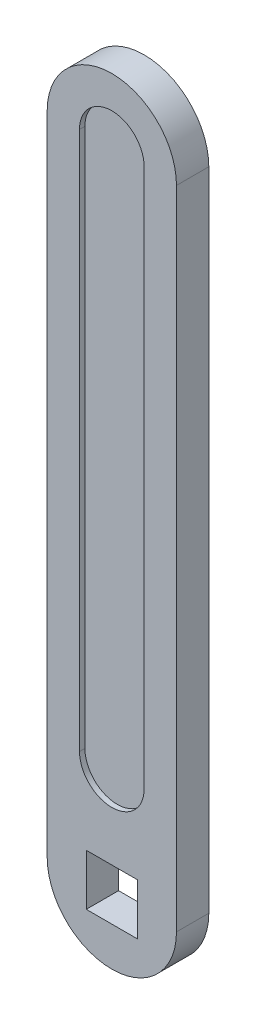
from build123d import *

# Parameters (mm, degrees)
SKETCH_1_W          = 9.5
SKETCH_1_H          = 9.5
EXTRUDE_1_DEPTH     = 3
CUT_EXTRUDE_1_DEPTH = 1


with BuildPart() as part:
    # 草图1 → 凸台-拉伸1 (new body, symmetric)
    with BuildSketch(Plane.XY):
        with BuildLine():
            Line((-12, 0), (-12, 120))
            ThreePointArc((-12, 120), (0, 132), (12, 120))
            Line((12, 120), (12, 0))
            ThreePointArc((12, 0), (0, -12), (-12, 0))
        make_face()
        Rectangle(SKETCH_1_W, SKETCH_1_H, mode=Mode.SUBTRACT)
    extrude(amount=EXTRUDE_1_DEPTH, both=True)

    # 草图2 → 切除-拉伸1 (cut)
    with BuildSketch(Plane.XY.offset(3)):
        with BuildLine():
            Line((-6, 20), (-6, 120))
            ThreePointArc((-6, 120), (0, 126), (6, 120))
            Line((6, 120), (6, 20))
            ThreePointArc((6, 20), (0, 14), (-6, 20))
        make_face()
    cut_extrude_1 = extrude(amount=-CUT_EXTRUDE_1_DEPTH, mode=Mode.SUBTRACT)

    # 镜向1: 切除-拉伸1 across plane
    add(cut_extrude_1.mirror(Plane.XY), mode=Mode.SUBTRACT)


solid = part.part
